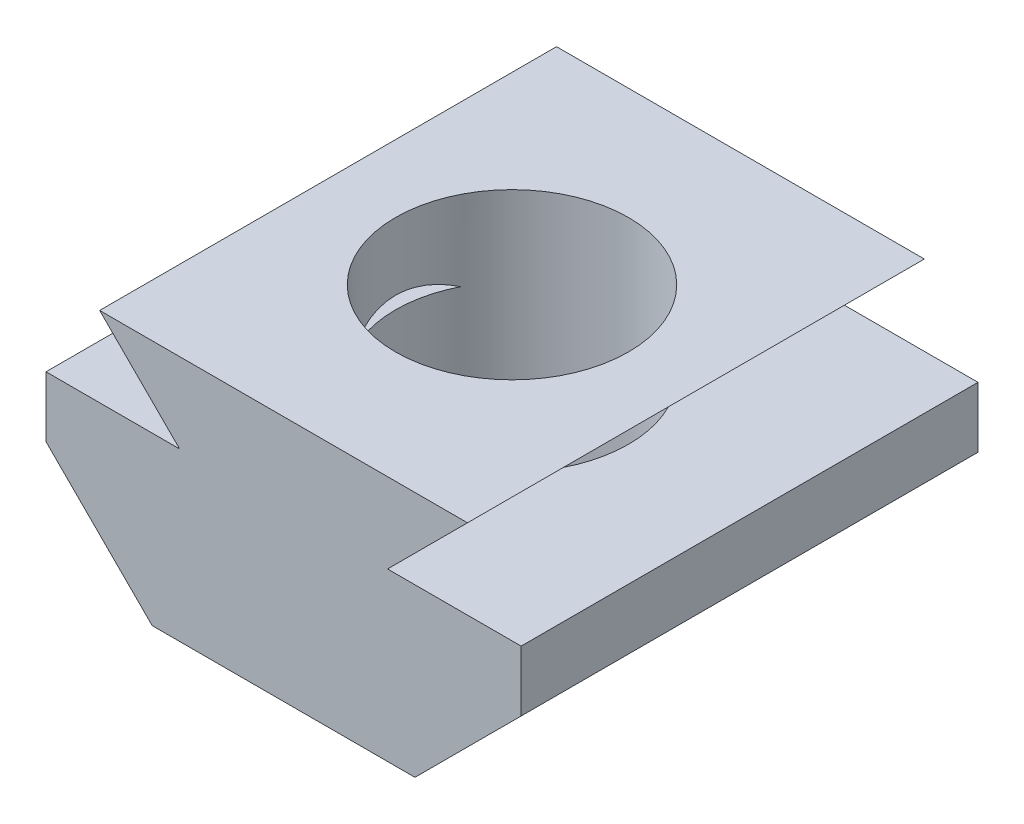
from build123d import *

# Parameters (mm, degrees)
SALIENTE_EXTRUIR1_DEPTH = 10
CROQUIS2_R              = 2.55
CORTAR_EXTRUIR1_DEPTH   = 6.4


with BuildPart() as part:
    # Croquis1 → Saliente-Extruir1 (new body)
    with BuildSketch(Plane.XY):
        Polygon((-4.025735931, -0.3), (4.025735931, -0.3), (2.275735931, -2.05), (5.2, -2.05), (5.2, -3.375735931), (2.875735931, -5.7), (-2.875735931, -5.7), (-5.2, -3.375735931), (-5.2, -2.05), (-2.275735931, -2.05), align=None)
    extrude(amount=SALIENTE_EXTRUIR1_DEPTH)

    # Croquis2 → Cortar-Extruir1 (cut, through all)
    with BuildSketch(Plane(origin=(0, -0.3, 0), x_dir=(1, 0, 0), z_dir=(0, 1, 0))):
        with Locations((0, -5)):
            Circle(CROQUIS2_R)
    extrude(amount=-CORTAR_EXTRUIR1_DEPTH, mode=Mode.SUBTRACT)


solid = part.part
